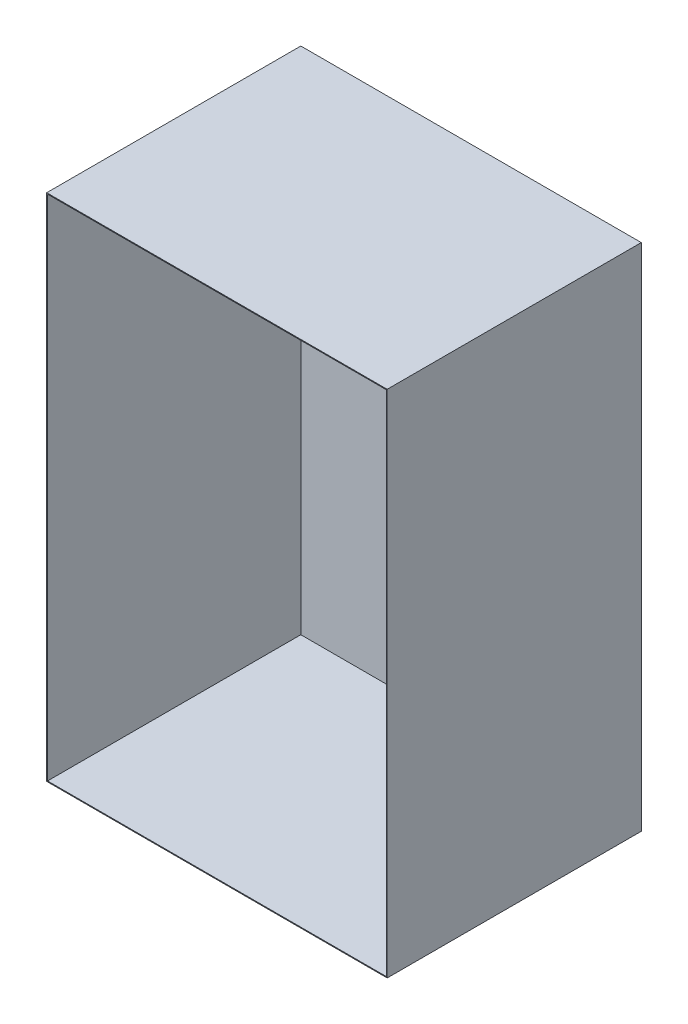
from build123d import *

# Parameters (mm, degrees)
SKETCH1_W           = 402
SKETCH1_H           = 602
SKETCH1_W_2         = 400
SKETCH1_H_2         = 600
BOSS_EXTRUDE1_DEPTH = 299
SKETCH2_W           = 402
SKETCH2_H           = 602
BOSS_EXTRUDE2_DEPTH = 1


with BuildPart() as part:
    # Sketch1 → Boss-Extrude1 (new body)
    with BuildSketch(Plane.XY):
        Rectangle(SKETCH1_W, SKETCH1_H)
        Rectangle(SKETCH1_W_2, SKETCH1_H_2, mode=Mode.SUBTRACT)
    extrude(amount=BOSS_EXTRUDE1_DEPTH)

    # Sketch2 → Boss-Extrude2 (add)
    with BuildSketch(Plane(origin=(0, 0, 0), x_dir=(-1, 0, 0), z_dir=(0, 0, -1))):
        Rectangle(SKETCH2_W, SKETCH2_H)
    extrude(amount=BOSS_EXTRUDE2_DEPTH)


solid = part.part
